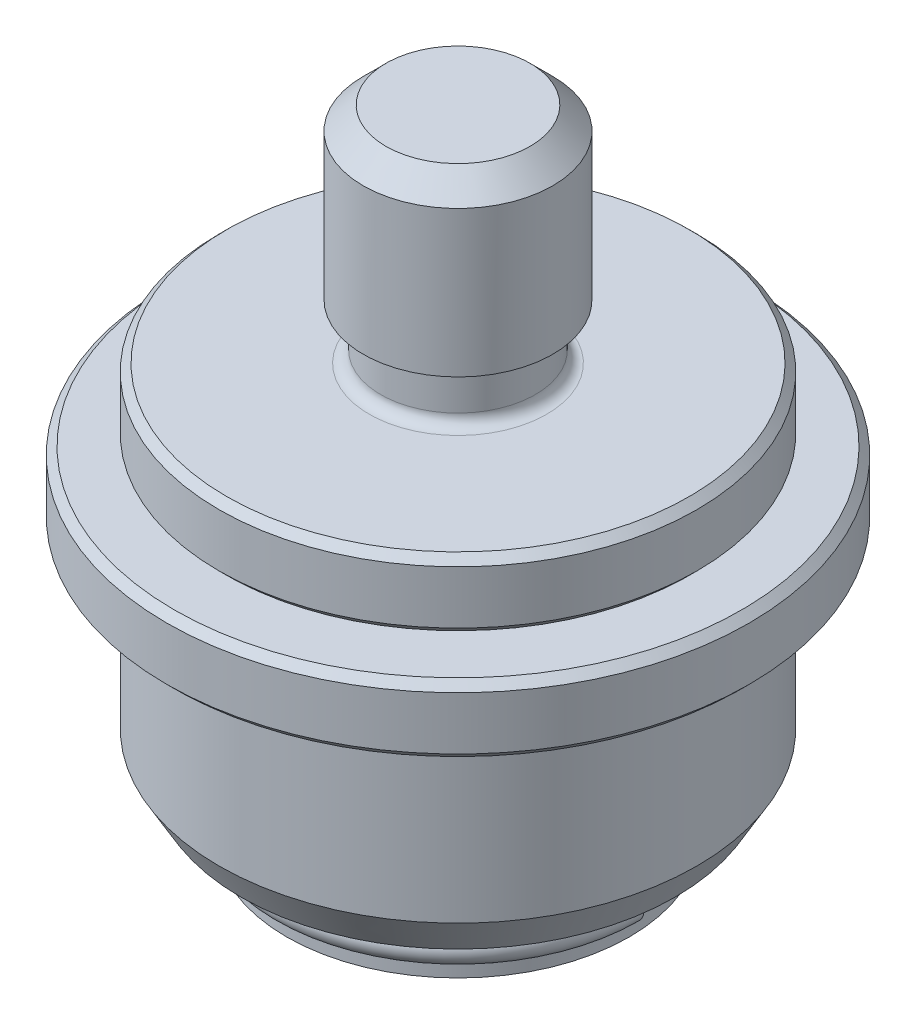
from build123d import *

# Parameters (mm, degrees)
CHAMFER1_SIZE  = 0.508
CHAMFER2_SIZE  = 1.524
CHAMFER3_SIZE  = 0.508
SKETCH3_R      = 0.9652
REVOLVE3_ANGLE = 315


with BuildPart() as part:
    # Sketch1 → Revolve1 (revolve)
    with BuildSketch(Plane.XY, mode=Mode.PRIVATE) as revolve1_sk:
        with BuildLine():
            Line((0, 14.986), (0, -15.5321))
            Line((0, -15.5321), (3.4925, -15.5321))
            Line((3.4925, -15.5321), (8.0264, -20.066))
            Line((8.0264, -20.066), (8.0264, -26.035))
            ThreePointArc((8.0264, -26.035), (8.472769265, -27.112630735), (9.5504, -27.559))
            Line((9.5504, -27.559), (11.4808, -27.559))
            Line((11.4808, -27.559), (11.4808, -26.5938))
            ThreePointArc((11.4808, -26.5938), (10.4648, -25.5778), (11.4808, -24.5618))
            Line((11.4808, -24.5618), (11.4808, -4.572))
            Line((11.4808, -4.572), (16.002, -4.572))
            Line((16.002, -4.572), (16.002, 0))
            Line((16.002, 0), (5.9436, 0))
            ThreePointArc((5.9436, 0), (5.404784633, 0.223184633), (5.1816, 0.762))
            Line((5.1816, 0.762), (5.1816, 3.683))
            Line((5.1816, 3.683), (6.35, 3.683))
            Line((6.35, 3.683), (6.35, 14.986))
            Line((6.35, 14.986), (0, 14.986))
        make_face()
    revolve(revolve1_sk.sketch.rotate(Axis((0, 14.986, 0), (0, 1, 0)), 90), axis=Axis((0, 14.986, 0), (0, 1, 0)))  # turned: the seam where the file's is

    # Chamfer1
    chamfer1_edges = [part.edges().sort_by_distance(p)[0] for p in [
        (0, -4.572, 16.002),
        (0, 0, 16.002),
    ]]
    chamfer(chamfer1_edges, length=CHAMFER1_SIZE)

    # Chamfer2
    chamfer2_edges = [part.edges().sort_by_distance(p)[0] for p in [
        (0, 14.986, 6.35),
    ]]
    chamfer(chamfer2_edges, length=CHAMFER2_SIZE)


with BuildPart() as body_2:
    # Sketch2 → Revolve2 (revolve)
    with BuildSketch(Plane.XY, mode=Mode.PRIVATE) as revolve2_sk:
        with BuildLine():
            Line((11.5316, -4.826), (11.5316, -20.7264))
            Line((11.5316, -20.7264), (12.192, -20.7264))
            ThreePointArc((12.192, -20.7264), (12.91042049, -21.02397951), (13.208, -21.7424))
            Line((13.208, -21.7424), (13.208, -23.7236))
            Line((13.208, -23.7236), (14.535530316, -23.7236))
            Line((14.535530316, -23.7236), (16.002, -21.1836))
            Line((16.002, -21.1836), (16.002, -10.16))
            ThreePointArc((16.002, -10.16), (16.225184633, -9.621184633), (16.764, -9.398))
            Line((16.764, -9.398), (19.5072, -9.398))
            Line((19.5072, -9.398), (19.5072, -4.826))
            Line((19.5072, -4.826), (11.5316, -4.826))
        make_face()
    revolve(revolve2_sk.sketch.rotate(Axis((0, 0, 0), (0, 1, 0)), 90), axis=Axis((0, 0, 0), (0, 1, 0)))  # turned: the seam where the file's is

    # Chamfer3
    chamfer3_edges = [body_2.edges().sort_by_distance(p)[0] for p in [
        (0, -4.826, 19.5072),
        (0, -9.398, 19.5072),
    ]]
    chamfer(chamfer3_edges, length=CHAMFER3_SIZE)


with BuildPart() as body_3:
    # Sketch3 → Revolve3 (revolve)
    with BuildSketch(Plane.XY):
        with Locations((11.4808, -25.5778)):
            Circle(SKETCH3_R)
    revolve(axis=Axis((0, 0, 0), (0, -1, 0)), revolution_arc=REVOLVE3_ANGLE)


solid = Compound([part.part, body_2.part, body_3.part])
